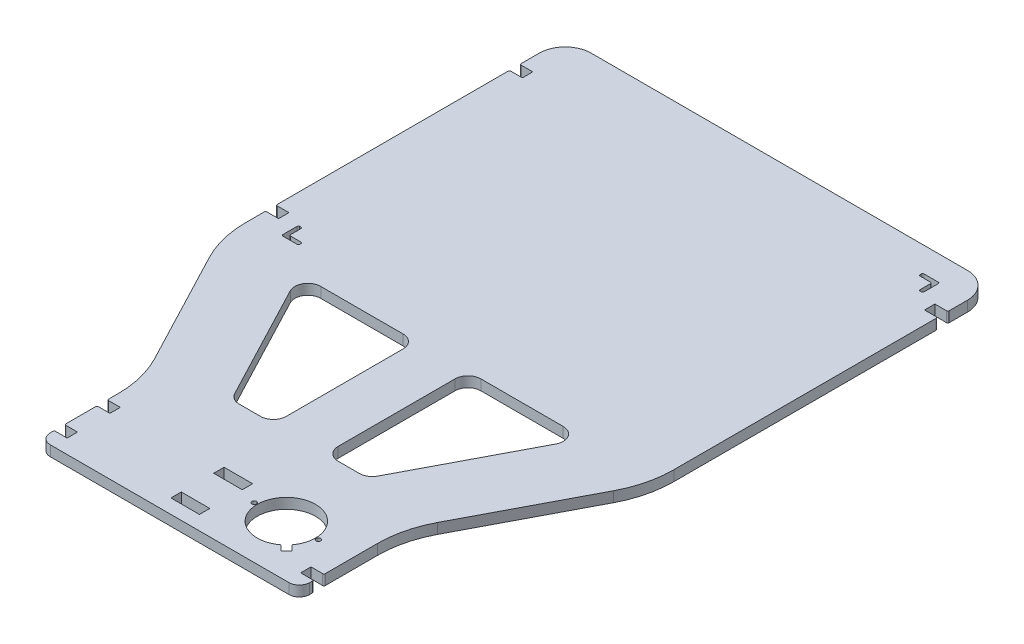
from build123d import *

# Parameters (mm, degrees)
SKETCH1_W           = 22
SKETCH1_H           = 8
SKETCH1_R           = 1.75
BOSS_EXTRUDE1_DEPTH = 8


with BuildPart() as part:
    # Sketch1 → Boss-Extrude1 (new body)
    with BuildSketch(Plane(origin=(0, 0, 0), x_dir=(1, 0, 0), z_dir=(0, 1, 0))):
        with BuildLine():
            Line((-92, 0), (92, 0))
            ThreePointArc((92, 0), (97.656854249, 2.343145751), (100, 8))
            Line((100, 8), (100, 10))
            ThreePointArc((100, 10), (99.707106781, 10.707106781), (99, 11))
            Line((99, 11), (90, 11))
            Line((90, 11), (90, 19))
            Line((90, 19), (99, 19))
            ThreePointArc((99, 19), (99.707106781, 19.292893219), (100, 20))
            Line((100, 20), (100, 60.303296759))
            ThreePointArc((100, 60.303296759), (102.319800375, 79.428844756), (109.144664654, 97.445206417))
            Line((109.144664654, 97.445206417), (155.855335346, 186.554793583))
            ThreePointArc((155.855335346, 186.554793583), (162.680199625, 204.571155244), (165, 223.696703241))
            Line((165, 223.696703241), (165, 426))
            ThreePointArc((165, 426), (164.707106781, 426.707106781), (164, 427))
            Line((164, 427), (155, 427))
            Line((155, 427), (155, 435))
            Line((155, 435), (164, 435))
            ThreePointArc((164, 435), (164.707106781, 435.292893219), (165, 436))
            Line((165, 436), (165, 450))
            ThreePointArc((165, 450), (159.142135624, 464.142135624), (145, 470))
            Line((145, 470), (-145, 470))
            ThreePointArc((-145, 470), (-159.142135624, 464.142135624), (-165, 450))
            Line((-165, 450), (-165, 436))
            ThreePointArc((-165, 436), (-164.707106781, 435.292893219), (-164, 435))
            Line((-164, 435), (-155, 435))
            Line((-155, 435), (-155, 427))
            Line((-155, 427), (-164, 427))
            ThreePointArc((-164, 427), (-164.707106781, 426.707106781), (-165, 426))
            Line((-165, 426), (-165, 248))
            ThreePointArc((-165, 248), (-164.707106781, 247.292893219), (-164, 247))
            Line((-164, 247), (-155, 247))
            Line((-155, 247), (-155, 239))
            Line((-155, 239), (-164, 239))
            ThreePointArc((-164, 239), (-164.707106781, 238.707106781), (-165, 238))
            Line((-165, 238), (-165, 223.696703241))
            ThreePointArc((-165, 223.696703241), (-162.680199625, 204.571155244), (-155.855335346, 186.554793583))
            Line((-155.855335346, 186.554793583), (-109.144664654, 97.445206417))
            ThreePointArc((-109.144664654, 97.445206417), (-102.319800375, 79.428844756), (-100, 60.303296759))
            Line((-100, 60.303296759), (-100, 53))
            ThreePointArc((-100, 53), (-99.707106781, 52.292893219), (-99, 52))
            Line((-99, 52), (-90, 52))
            Line((-90, 52), (-90, 44))
            Line((-90, 44), (-99, 44))
            ThreePointArc((-99, 44), (-99.707106781, 43.707106781), (-100, 43))
            Line((-100, 43), (-100, 20))
            ThreePointArc((-100, 20), (-99.707106781, 19.292893219), (-99, 19))
            Line((-99, 19), (-90, 19))
            Line((-90, 19), (-90, 11))
            Line((-90, 11), (-99, 11))
            ThreePointArc((-99, 11), (-99.707106781, 10.707106781), (-100, 10))
            Line((-100, 10), (-100, 8))
            ThreePointArc((-100, 8), (-97.656854249, 2.343145751), (-92, 0))
        make_face()
        with BuildLine():
            Line((-55.146951484, 105.357261293), (-102.324370839, 195.357261293))
            ThreePointArc((-102.324370839, 195.357261293), (-102.023953996, 205.175548905), (-93.467453921, 210))
            Line((-93.467453921, 210), (-30, 210))
            ThreePointArc((-30, 210), (-22.928932188, 207.071067812), (-20, 200))
            Line((-20, 200), (-20, 110))
            ThreePointArc((-20, 110), (-22.928932188, 102.928932188), (-30, 100))
            Line((-30, 100), (-46.290034566, 100))
            ThreePointArc((-46.290034566, 100), (-51.465583471, 101.443499925), (-55.146951484, 105.357261293))
        make_face(mode=Mode.SUBTRACT)
        with Locations((1, 15)):
            Rectangle(SKETCH1_W, SKETCH1_H, mode=Mode.SUBTRACT)
        with Locations((1, 48)):
            Rectangle(SKETCH1_W, SKETCH1_H, mode=Mode.SUBTRACT)
        with Locations((25.26, 40)):
            Circle(SKETCH1_R, mode=Mode.SUBTRACT)
        with BuildLine():
            ThreePointArc((63.646526688, 22.110832625), (34.090097423, 55.909902577), (67.889167375, 26.353473312))
            Line((67.889167375, 26.353473312), (72.131808062, 22.110832625))
            Line((72.131808062, 22.110832625), (67.889167375, 17.868191938))
            Line((67.889167375, 17.868191938), (63.646526688, 22.110832625))
        make_face(mode=Mode.SUBTRACT)
        with Locations((74.74, 40)):
            Circle(SKETCH1_R, mode=Mode.SUBTRACT)
        with BuildLine():
            ThreePointArc((20, 200), (22.928932188, 207.071067812), (30, 210))
            Line((30, 210), (93.467453921, 210))
            ThreePointArc((93.467453921, 210), (102.023953996, 205.175548905), (102.324370839, 195.357261293))
            Line((102.324370839, 195.357261293), (55.146951484, 105.357261293))
            ThreePointArc((55.146951484, 105.357261293), (51.465583471, 101.443499925), (46.290034566, 100))
            Line((46.290034566, 100), (30, 100))
            ThreePointArc((30, 100), (22.928932188, 102.928932188), (20, 110))
            Line((20, 110), (20, 200))
        make_face(mode=Mode.SUBTRACT)
        with BuildLine():
            ThreePointArc((-140.7, 242), (-139.992893219, 241.707106781), (-139.7, 241))
            Line((-139.7, 241), (-139.7, 233))
            ThreePointArc((-139.7, 233), (-139.407106781, 232.292893219), (-138.7, 232))
            Line((-138.7, 232), (-130.7, 232))
            ThreePointArc((-130.7, 232), (-129.992893219, 231.707106781), (-129.7, 231))
            Line((-129.7, 231), (-129.7, 230))
            ThreePointArc((-129.7, 230), (-129.992893219, 229.292893219), (-130.7, 229))
            Line((-130.7, 229), (-141.7, 229))
            ThreePointArc((-141.7, 229), (-142.407106781, 229.292893219), (-142.7, 230))
            Line((-142.7, 230), (-142.7, 241))
            ThreePointArc((-142.7, 241), (-142.407106781, 241.707106781), (-141.7, 242))
            Line((-141.7, 242), (-140.7, 242))
        make_face(mode=Mode.SUBTRACT)
        with BuildLine():
            Line((129.7, 448.9), (129.7, 449.9))
            ThreePointArc((129.7, 449.9), (129.992893219, 450.607106781), (130.7, 450.9))
            Line((130.7, 450.9), (141.7, 450.9))
            ThreePointArc((141.7, 450.9), (142.407106781, 450.607106781), (142.7, 449.9))
            Line((142.7, 449.9), (142.7, 438.9))
            ThreePointArc((142.7, 438.9), (142.407106781, 438.192893219), (141.7, 437.9))
            Line((141.7, 437.9), (140.7, 437.9))
            ThreePointArc((140.7, 437.9), (139.992893219, 438.192893219), (139.7, 438.9))
            Line((139.7, 438.9), (139.7, 446.9))
            ThreePointArc((139.7, 446.9), (139.407106781, 447.607106781), (138.7, 447.9))
            Line((138.7, 447.9), (130.7, 447.9))
            ThreePointArc((130.7, 447.9), (129.992893219, 448.192893219), (129.7, 448.9))
        make_face(mode=Mode.SUBTRACT)
    extrude(amount=BOSS_EXTRUDE1_DEPTH)


solid = part.part
